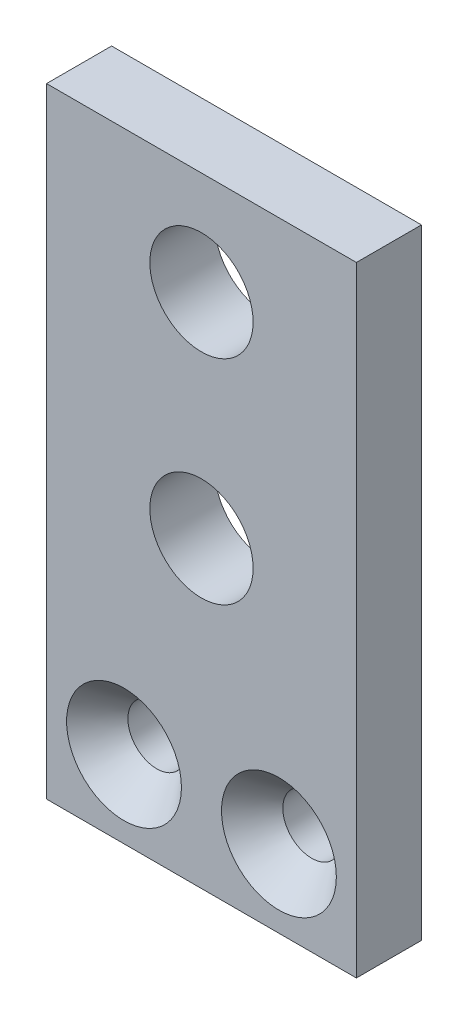
from build123d import *

# Parameters (mm, degrees)
SKETCH1_W                                 = 9.525
SKETCH1_H                                 = 19.05
BOSS_EXTRUDE1_DEPTH                       = 2
CSK_FOR_0_FLAT_HEAD_MACHINE_SCREW_2_COUNT = 2
CSK_FOR_0_FLAT_HEAD_MACHINE_SCREW_2_PITCH = 4.7625
F_1_8_0_125_DIAMETER_HOLE1_D              = 3.175
F_1_8_0_125_DIAMETER_HOLE1_DEPTH          = 4.064
F_1_8_0_125_DIAMETER_HOLE1_TIP            = 0.953866233


with BuildPart() as part:
    # Sketch1 → Boss-Extrude1 (new body)
    with BuildSketch(Plane.XY):
        Rectangle(SKETCH1_W, SKETCH1_H)
    extrude(amount=BOSS_EXTRUDE1_DEPTH)

    # Sketch2 → CSK for #0 Flat Head Machine Screw (100)1 (revolve, cut)
    with BuildSketch(Plane(origin=(-2.38125, -7.14375, 2), x_dir=(0, -1, 0), z_dir=(1, 0, 0))):
        Polygon((0, 0), (0, 2), (0.889, 2), (0.889, 1.008067835), (1.7653, 0), align=None)
    csk_for_0_flat_head_machine_screw_100 = revolve(axis=Axis((-2.38125, -7.14375, 8.35), (0, 0, -1)), mode=Mode.SUBTRACT)

    # CSK for _0 Flat Head Machine Screw _ 2: CSK for #0 Flat Head Machine Screw (100)1 ×2
    with Locations(*[(i * CSK_FOR_0_FLAT_HEAD_MACHINE_SCREW_2_PITCH, 0, 0) for i in range(1, CSK_FOR_0_FLAT_HEAD_MACHINE_SCREW_2_COUNT)]):
        add(csk_for_0_flat_head_machine_screw_100, mode=Mode.SUBTRACT)

    # 1/8 (0.125) Diameter Hole1
    with Locations(Plane.XY.offset(2)):
        with Locations((0, 6.35), (0, -0.2032)):
            Hole(F_1_8_0_125_DIAMETER_HOLE1_D / 2, depth=F_1_8_0_125_DIAMETER_HOLE1_DEPTH)
            with Locations((0, 0, -(F_1_8_0_125_DIAMETER_HOLE1_DEPTH + F_1_8_0_125_DIAMETER_HOLE1_TIP / 2))):  # 118° drill point
                Cone(0, F_1_8_0_125_DIAMETER_HOLE1_D / 2, F_1_8_0_125_DIAMETER_HOLE1_TIP, mode=Mode.SUBTRACT)


solid = part.part
